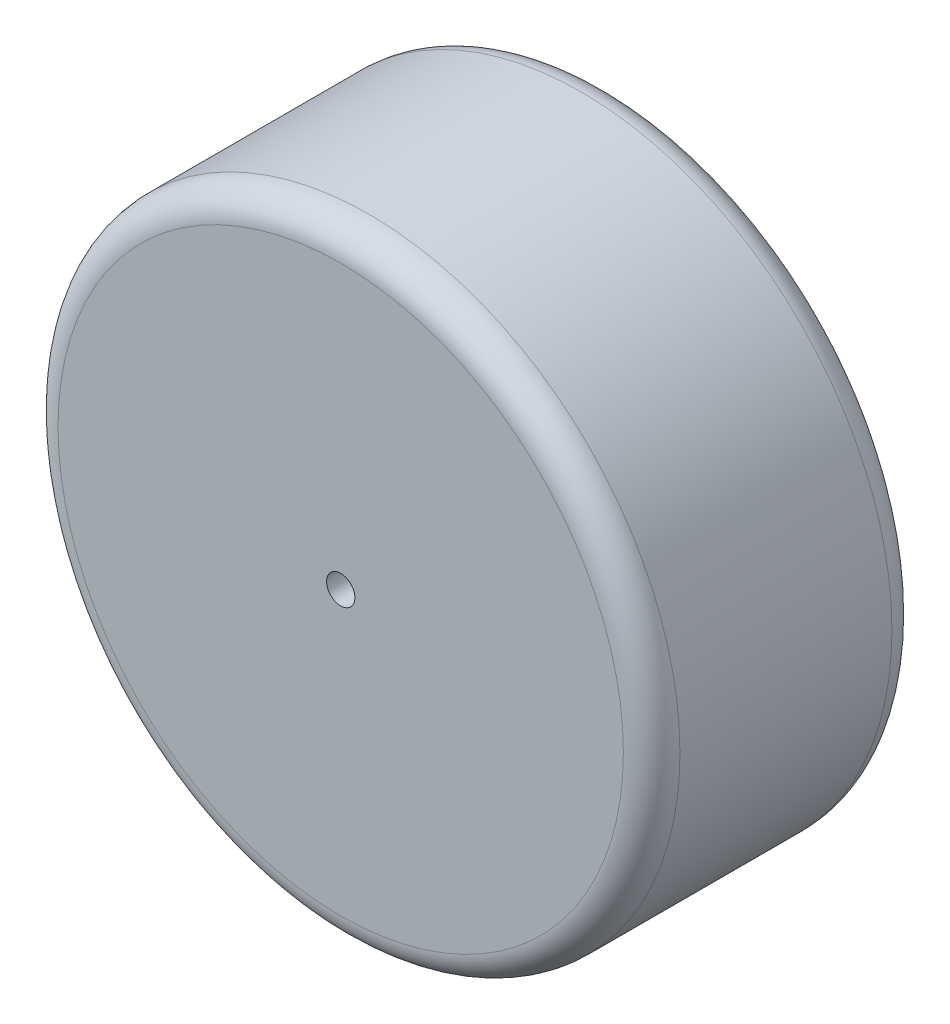
from build123d import *

# Parameters (mm, degrees)
ESQUISSE1_R        = 11
ESQUISSE1_R_2      = 0.5
BOSS_EXTRU_1_DEPTH = 9.5
CONG_1_R           = 1


with BuildPart() as part:
    # Esquisse1 → Boss.-Extru.1 (new body)
    with BuildSketch(Plane.XY):
        Circle(ESQUISSE1_R)
        Circle(ESQUISSE1_R_2, mode=Mode.SUBTRACT)
    extrude(amount=BOSS_EXTRU_1_DEPTH)

    # Congé1
    cong_1_edges = [part.edges().sort_by_distance(p)[0] for p in [
        (-11, 0, 0),
        (-11, 0, 9.5),
    ]]
    fillet(cong_1_edges, radius=CONG_1_R)


solid = part.part
